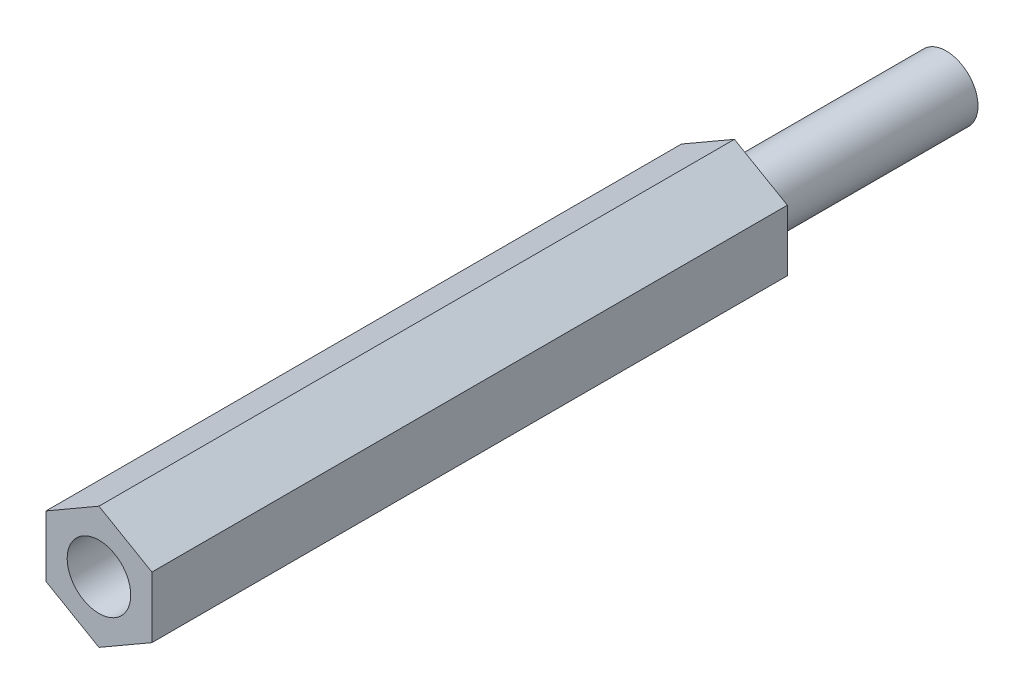
from build123d import *

# Parameters (mm, degrees)
ESQUISSE1_R             = 1.5
BOSS_EXTRU_2_DEPTH      = 30
ESQUISSE3_R             = 1.5
BOSS_EXTRU_3_DEPTH      = 10
BOSS_EXTRU_3_DEPTH_BACK = 20


with BuildPart() as part:
    # Esquisse1 → Boss.-Extru.2 (new body)
    with BuildSketch(Plane.XY):
        Polygon((0, -2.886751346), (2.5, -1.443375673), (2.5, 1.443375673), (0, 2.886751346), (-2.5, 1.443375673), (-2.5, -1.443375673), align=None)
        Circle(ESQUISSE1_R, mode=Mode.SUBTRACT)
    extrude(amount=BOSS_EXTRU_2_DEPTH)

    # Esquisse3 → Boss.-Extru.3 (add, two sides)
    with BuildSketch(Plane(origin=(0, 0, 0), x_dir=(-1, 0, 0), z_dir=(0, 0, -1))) as boss_extru_3_sk:
        Circle(ESQUISSE3_R)
    extrude(amount=BOSS_EXTRU_3_DEPTH)
    extrude(boss_extru_3_sk.sketch, amount=-BOSS_EXTRU_3_DEPTH_BACK)


solid = part.part
